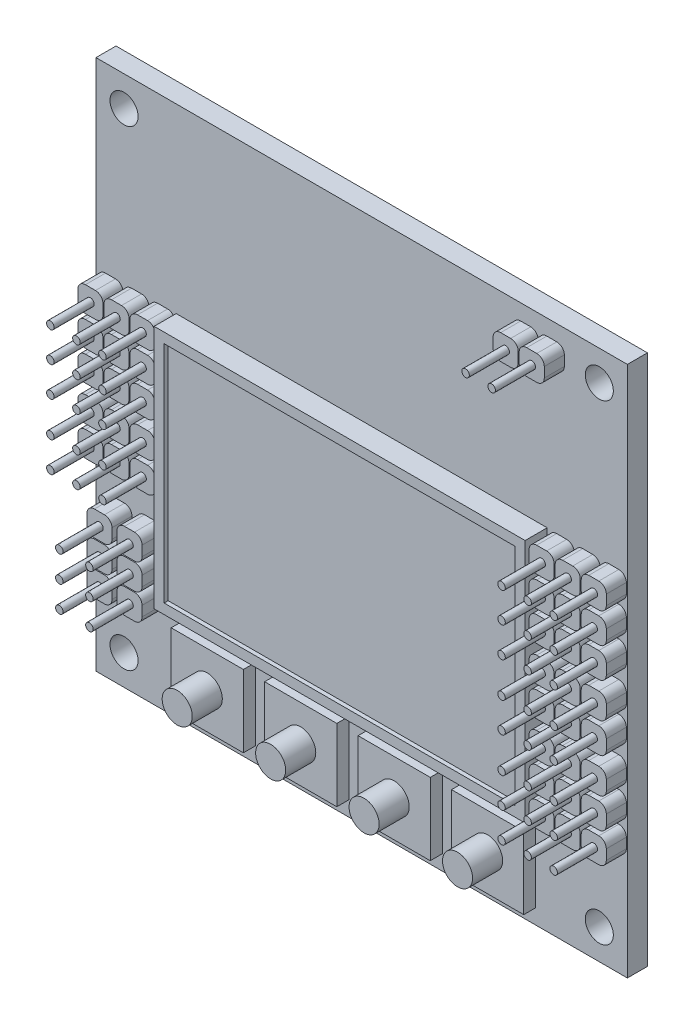
from build123d import *

# Parameters (mm, degrees)
SKETCH1_W                  = 53
SKETCH1_H                  = 53
BOSS_EXTRUDE1_DEPTH        = 2
SKETCH2_R                  = 1.4
CUT_EXTRUDE1_DEPTH         = 2
BOSS_EXTRUDE2_DEPTH        = 2
SKETCH4_R                  = 0.375
BOSS_EXTRUDE3_DEPTH        = 4
LPATTERN1_COUNT            = 3
LPATTERN1_PITCH            = 2.6
LPATTERN2_COUNT            = 3
LPATTERN2_PITCH            = 3
LPATTERN2_COPY_1_DEPTH     = 2
LPATTERN2_COPY_2_DEPTH     = 2
LPATTERN2_COPY_3_DEPTH     = 2
LPATTERN2_COPY_4_DEPTH     = 2
LPATTERN2_COPY_5_SKETCH_R  = 0.375
LPATTERN2_COPY_5_DEPTH     = 4
LPATTERN2_COPY_6_SKETCH_R  = 0.375
LPATTERN2_COPY_6_DEPTH     = 4
LPATTERN2_COPY_7_SKETCH_R  = 0.375
LPATTERN2_COPY_7_DEPTH     = 4
LPATTERN2_COPY_8_SKETCH_R  = 0.375
LPATTERN2_COPY_8_DEPTH     = 4
LPATTERN3_COUNT            = 2
LPATTERN3_PITCH            = 9.5
LPATTERN3_COPY_1_DEPTH     = 2
LPATTERN3_COPY_2_DEPTH     = 2
LPATTERN3_COPY_3_SKETCH_R  = 0.375
LPATTERN3_COPY_3_DEPTH     = 4
LPATTERN3_COPY_4_SKETCH_R  = 0.375
LPATTERN3_COPY_4_DEPTH     = 4
LPATTERN4_COUNT            = 2
LPATTERN4_PITCH            = 12.5
LPATTERN4_COPY_1_DEPTH     = 2
LPATTERN4_COPY_2_DEPTH     = 2
LPATTERN4_COPY_3_SKETCH_R  = 0.375
LPATTERN4_COPY_3_DEPTH     = 4
LPATTERN4_COPY_4_SKETCH_R  = 0.375
LPATTERN4_COPY_4_DEPTH     = 4
LPATTERN5_COUNT            = 2
LPATTERN5_PITCH            = 45
LPATTERN5_COPY_1_DEPTH     = 2
LPATTERN5_COPY_2_SKETCH_R  = 0.375
LPATTERN5_COPY_2_DEPTH     = 4
LPATTERN5_COPY_3_DEPTH     = 2
LPATTERN5_COPY_4_DEPTH     = 2
LPATTERN5_COPY_5_SKETCH_R  = 0.375
LPATTERN5_COPY_5_DEPTH     = 4
LPATTERN5_COPY_6_SKETCH_R  = 0.375
LPATTERN5_COPY_6_DEPTH     = 4
LPATTERN5_COPY_7_DEPTH     = 2
LPATTERN5_COPY_8_SKETCH_R  = 0.375
LPATTERN5_COPY_8_DEPTH     = 4
LPATTERN5_COPY_9_DEPTH     = 2
LPATTERN5_COPY_10_DEPTH    = 2
LPATTERN5_COPY_11_SKETCH_R = 0.375
LPATTERN5_COPY_11_DEPTH    = 4
LPATTERN5_COPY_12_SKETCH_R = 0.375
LPATTERN5_COPY_12_DEPTH    = 4
LPATTERN5_COPY_13_DEPTH    = 2
LPATTERN5_COPY_14_DEPTH    = 2
LPATTERN5_COPY_15_SKETCH_R = 0.375
LPATTERN5_COPY_15_DEPTH    = 4
LPATTERN5_COPY_16_SKETCH_R = 0.375
LPATTERN5_COPY_16_DEPTH    = 4
LPATTERN5_COPY_17_DEPTH    = 2
LPATTERN5_COPY_18_DEPTH    = 2
LPATTERN5_COPY_19_DEPTH    = 2
LPATTERN5_COPY_20_DEPTH    = 2
LPATTERN5_COPY_21_SKETCH_R = 0.375
LPATTERN5_COPY_21_DEPTH    = 4
LPATTERN5_COPY_22_SKETCH_R = 0.375
LPATTERN5_COPY_22_DEPTH    = 4
LPATTERN5_COPY_23_SKETCH_R = 0.375
LPATTERN5_COPY_23_DEPTH    = 4
LPATTERN5_COPY_24_SKETCH_R = 0.375
LPATTERN5_COPY_24_DEPTH    = 4
LPATTERN5_COPY_25_DEPTH    = 2
LPATTERN5_COPY_26_DEPTH    = 2
LPATTERN5_COPY_27_SKETCH_R = 0.375
LPATTERN5_COPY_27_DEPTH    = 4
LPATTERN5_COPY_28_SKETCH_R = 0.375
LPATTERN5_COPY_28_DEPTH    = 4
LPATTERN6_COUNT            = 2
LPATTERN6_PITCH            = 16
LPATTERN6_COPY_1_DEPTH     = 2
LPATTERN6_COPY_2_DEPTH     = 2
LPATTERN6_COPY_3_SKETCH_R  = 0.375
LPATTERN6_COPY_3_DEPTH     = 4
LPATTERN6_COPY_4_SKETCH_R  = 0.375
LPATTERN6_COPY_4_DEPTH     = 4
LPATTERN6_COPY_5_DEPTH     = 2
LPATTERN6_COPY_6_DEPTH     = 2
LPATTERN6_COPY_7_DEPTH     = 2
LPATTERN6_COPY_8_DEPTH     = 2
LPATTERN6_COPY_9_SKETCH_R  = 0.375
LPATTERN6_COPY_9_DEPTH     = 4
LPATTERN6_COPY_10_SKETCH_R = 0.375
LPATTERN6_COPY_10_DEPTH    = 4
LPATTERN6_COPY_11_SKETCH_R = 0.375
LPATTERN6_COPY_11_DEPTH    = 4
LPATTERN6_COPY_12_SKETCH_R = 0.375
LPATTERN6_COPY_12_DEPTH    = 4
LPATTERN6_COPY_13_DEPTH    = 2
LPATTERN6_COPY_14_DEPTH    = 2
LPATTERN6_COPY_15_SKETCH_R = 0.375
LPATTERN6_COPY_15_DEPTH    = 4
LPATTERN6_COPY_16_SKETCH_R = 0.375
LPATTERN6_COPY_16_DEPTH    = 4
SKETCH5_W                  = 7.2
SKETCH5_H                  = 7.2
BOSS_EXTRUDE4_DEPTH        = 1.2
SKETCH6_R                  = 1.5
BOSS_EXTRUDE5_DEPTH        = 3
LPATTERN7_COUNT            = 4
LPATTERN7_PITCH            = 9.32
BOSS_EXTRUDE6_DEPTH        = 2
SKETCH8_R                  = 0.375
BOSS_EXTRUDE7_DEPTH        = 4
LPATTERN8_COUNT            = 2
LPATTERN8_PITCH            = 2.6
SKETCH9_W                  = 37
SKETCH9_H                  = 24.4
BOSS_EXTRUDE8_DEPTH        = 2.2
SKETCH11_W                 = 35
SKETCH11_H                 = 22.4
CUT_EXTRUDE3_DEPTH         = 0.4
BOSS_EXTRUDE9_DEPTH        = 2
SKETCH13_R                 = 0.375
BOSS_EXTRUDE10_DEPTH       = 4
LPATTERN9_COUNT            = 3
LPATTERN9_PITCH            = 2.6
LPATTERN10_COUNT           = 2
LPATTERN10_PITCH           = 3
LPATTERN10_COPY_1_DEPTH    = 2
LPATTERN10_COPY_2_DEPTH    = 2
LPATTERN10_COPY_3_SKETCH_R = 0.375
LPATTERN10_COPY_3_DEPTH    = 4
LPATTERN10_COPY_4_SKETCH_R = 0.375
LPATTERN10_COPY_4_DEPTH    = 4


with BuildPart() as part:
    # Sketch1 → Boss-Extrude1 (new body)
    with BuildSketch(Plane.XY):
        with Locations((26.5, 26.5)):
            Rectangle(SKETCH1_W, SKETCH1_H)
    extrude(amount=BOSS_EXTRUDE1_DEPTH)

    # Sketch2 → Cut-Extrude1 (cut)
    with BuildSketch(Plane.XY.offset(2)):
        with Locations((50.2, 50)):
            Circle(SKETCH2_R)
        with Locations((2.8, 50)):
            Circle(SKETCH2_R)
        with Locations((50.2, 3)):
            Circle(SKETCH2_R)
        with Locations((2.8, 3)):
            Circle(SKETCH2_R)
    extrude(amount=-CUT_EXTRUDE1_DEPTH, mode=Mode.SUBTRACT)

    # Sketch3 → Boss-Extrude2 (add)
    with BuildSketch(Plane.XY.offset(2)):
        with BuildLine():
            Line((45.947892019, 34.858264614), (46.947892019, 34.858264614))
            ThreePointArc((46.947892019, 34.858264614), (47.478222105, 34.6385947), (47.697892019, 34.108264614))
            Line((47.697892019, 34.108264614), (47.697892019, 33.108264614))
            ThreePointArc((47.697892019, 33.108264614), (47.478222105, 32.577934528), (46.947892019, 32.358264614))
            Line((46.947892019, 32.358264614), (45.947892019, 32.358264614))
            ThreePointArc((45.947892019, 32.358264614), (45.417561933, 32.577934528), (45.197892019, 33.108264614))
            Line((45.197892019, 33.108264614), (45.197892019, 34.108264614))
            ThreePointArc((45.197892019, 34.108264614), (45.417561933, 34.6385947), (45.947892019, 34.858264614))
        make_face()
    boss_extrude2 = extrude(amount=BOSS_EXTRUDE2_DEPTH)

    # Sketch4 → Boss-Extrude3 (add)
    with BuildSketch(Plane.XY.offset(4)):
        with Locations((46.447892019, 33.608264614)):
            Circle(SKETCH4_R)
    boss_extrude3 = extrude(amount=BOSS_EXTRUDE3_DEPTH)

    # LPattern1: Boss-Extrude2, Boss-Extrude3 ×3
    with Locations(*[(i * LPATTERN1_PITCH, 0, 0) for i in range(1, LPATTERN1_COUNT)]):
        add(boss_extrude2)
        add(boss_extrude3)

    # LPattern2: Boss-Extrude2, Boss-Extrude3 ×3
    with Locations(*[(0, -i * LPATTERN2_PITCH, 0) for i in range(1, LPATTERN2_COUNT)]):
        add(boss_extrude2)
        add(boss_extrude3)

    # LPattern2 copy 1 sketch → LPattern2 copy 1 (add)
    with BuildSketch(Plane(origin=(2.6, -3, 2), x_dir=(1, 0, 0), z_dir=(0, 0, 1))):
        with BuildLine():
            Line((45.947892019, 34.858264614), (46.947892019, 34.858264614))
            ThreePointArc((46.947892019, 34.858264614), (47.478222105, 34.6385947), (47.697892019, 34.108264614))
            Line((47.697892019, 34.108264614), (47.697892019, 33.108264614))
            ThreePointArc((47.697892019, 33.108264614), (47.478222105, 32.577934528), (46.947892019, 32.358264614))
            Line((46.947892019, 32.358264614), (45.947892019, 32.358264614))
            ThreePointArc((45.947892019, 32.358264614), (45.417561933, 32.577934528), (45.197892019, 33.108264614))
            Line((45.197892019, 33.108264614), (45.197892019, 34.108264614))
            ThreePointArc((45.197892019, 34.108264614), (45.417561933, 34.6385947), (45.947892019, 34.858264614))
        make_face()
    extrude(amount=LPATTERN2_COPY_1_DEPTH)

    # LPattern2 copy 2 sketch → LPattern2 copy 2 (add)
    with BuildSketch(Plane(origin=(2.6, -6, 2), x_dir=(1, 0, 0), z_dir=(0, 0, 1))):
        with BuildLine():
            Line((45.947892019, 34.858264614), (46.947892019, 34.858264614))
            ThreePointArc((46.947892019, 34.858264614), (47.478222105, 34.6385947), (47.697892019, 34.108264614))
            Line((47.697892019, 34.108264614), (47.697892019, 33.108264614))
            ThreePointArc((47.697892019, 33.108264614), (47.478222105, 32.577934528), (46.947892019, 32.358264614))
            Line((46.947892019, 32.358264614), (45.947892019, 32.358264614))
            ThreePointArc((45.947892019, 32.358264614), (45.417561933, 32.577934528), (45.197892019, 33.108264614))
            Line((45.197892019, 33.108264614), (45.197892019, 34.108264614))
            ThreePointArc((45.197892019, 34.108264614), (45.417561933, 34.6385947), (45.947892019, 34.858264614))
        make_face()
    extrude(amount=LPATTERN2_COPY_2_DEPTH)

    # LPattern2 copy 3 sketch → LPattern2 copy 3 (add)
    with BuildSketch(Plane(origin=(5.2, -3, 2), x_dir=(1, 0, 0), z_dir=(0, 0, 1))):
        with BuildLine():
            Line((45.947892019, 34.858264614), (46.947892019, 34.858264614))
            ThreePointArc((46.947892019, 34.858264614), (47.478222105, 34.6385947), (47.697892019, 34.108264614))
            Line((47.697892019, 34.108264614), (47.697892019, 33.108264614))
            ThreePointArc((47.697892019, 33.108264614), (47.478222105, 32.577934528), (46.947892019, 32.358264614))
            Line((46.947892019, 32.358264614), (45.947892019, 32.358264614))
            ThreePointArc((45.947892019, 32.358264614), (45.417561933, 32.577934528), (45.197892019, 33.108264614))
            Line((45.197892019, 33.108264614), (45.197892019, 34.108264614))
            ThreePointArc((45.197892019, 34.108264614), (45.417561933, 34.6385947), (45.947892019, 34.858264614))
        make_face()
    extrude(amount=LPATTERN2_COPY_3_DEPTH)

    # LPattern2 copy 4 sketch → LPattern2 copy 4 (add)
    with BuildSketch(Plane(origin=(5.2, -6, 2), x_dir=(1, 0, 0), z_dir=(0, 0, 1))):
        with BuildLine():
            Line((45.947892019, 34.858264614), (46.947892019, 34.858264614))
            ThreePointArc((46.947892019, 34.858264614), (47.478222105, 34.6385947), (47.697892019, 34.108264614))
            Line((47.697892019, 34.108264614), (47.697892019, 33.108264614))
            ThreePointArc((47.697892019, 33.108264614), (47.478222105, 32.577934528), (46.947892019, 32.358264614))
            Line((46.947892019, 32.358264614), (45.947892019, 32.358264614))
            ThreePointArc((45.947892019, 32.358264614), (45.417561933, 32.577934528), (45.197892019, 33.108264614))
            Line((45.197892019, 33.108264614), (45.197892019, 34.108264614))
            ThreePointArc((45.197892019, 34.108264614), (45.417561933, 34.6385947), (45.947892019, 34.858264614))
        make_face()
    extrude(amount=LPATTERN2_COPY_4_DEPTH)

    # LPattern2 copy 5 sketch → LPattern2 copy 5 (add)
    with BuildSketch(Plane(origin=(2.6, -3, 4), x_dir=(1, 0, 0), z_dir=(0, 0, 1))):
        with Locations((46.447892019, 33.608264614)):
            Circle(LPATTERN2_COPY_5_SKETCH_R)
    extrude(amount=LPATTERN2_COPY_5_DEPTH)

    # LPattern2 copy 6 sketch → LPattern2 copy 6 (add)
    with BuildSketch(Plane(origin=(2.6, -6, 4), x_dir=(1, 0, 0), z_dir=(0, 0, 1))):
        with Locations((46.447892019, 33.608264614)):
            Circle(LPATTERN2_COPY_6_SKETCH_R)
    extrude(amount=LPATTERN2_COPY_6_DEPTH)

    # LPattern2 copy 7 sketch → LPattern2 copy 7 (add)
    with BuildSketch(Plane(origin=(5.2, -3, 4), x_dir=(1, 0, 0), z_dir=(0, 0, 1))):
        with Locations((46.447892019, 33.608264614)):
            Circle(LPATTERN2_COPY_7_SKETCH_R)
    extrude(amount=LPATTERN2_COPY_7_DEPTH)

    # LPattern2 copy 8 sketch → LPattern2 copy 8 (add)
    with BuildSketch(Plane(origin=(5.2, -6, 4), x_dir=(1, 0, 0), z_dir=(0, 0, 1))):
        with Locations((46.447892019, 33.608264614)):
            Circle(LPATTERN2_COPY_8_SKETCH_R)
    extrude(amount=LPATTERN2_COPY_8_DEPTH)

    # LPattern3: Boss-Extrude2, Boss-Extrude3 ×2
    with Locations(*[(0, -i * LPATTERN3_PITCH, 0) for i in range(1, LPATTERN3_COUNT)]):
        add(boss_extrude2)
        add(boss_extrude3)

    # LPattern3 copy 1 sketch → LPattern3 copy 1 (add)
    with BuildSketch(Plane(origin=(2.6, -9.5, 2), x_dir=(1, 0, 0), z_dir=(0, 0, 1))):
        with BuildLine():
            Line((45.947892019, 34.858264614), (46.947892019, 34.858264614))
            ThreePointArc((46.947892019, 34.858264614), (47.478222105, 34.6385947), (47.697892019, 34.108264614))
            Line((47.697892019, 34.108264614), (47.697892019, 33.108264614))
            ThreePointArc((47.697892019, 33.108264614), (47.478222105, 32.577934528), (46.947892019, 32.358264614))
            Line((46.947892019, 32.358264614), (45.947892019, 32.358264614))
            ThreePointArc((45.947892019, 32.358264614), (45.417561933, 32.577934528), (45.197892019, 33.108264614))
            Line((45.197892019, 33.108264614), (45.197892019, 34.108264614))
            ThreePointArc((45.197892019, 34.108264614), (45.417561933, 34.6385947), (45.947892019, 34.858264614))
        make_face()
    extrude(amount=LPATTERN3_COPY_1_DEPTH)

    # LPattern3 copy 2 sketch → LPattern3 copy 2 (add)
    with BuildSketch(Plane(origin=(5.2, -9.5, 2), x_dir=(1, 0, 0), z_dir=(0, 0, 1))):
        with BuildLine():
            Line((45.947892019, 34.858264614), (46.947892019, 34.858264614))
            ThreePointArc((46.947892019, 34.858264614), (47.478222105, 34.6385947), (47.697892019, 34.108264614))
            Line((47.697892019, 34.108264614), (47.697892019, 33.108264614))
            ThreePointArc((47.697892019, 33.108264614), (47.478222105, 32.577934528), (46.947892019, 32.358264614))
            Line((46.947892019, 32.358264614), (45.947892019, 32.358264614))
            ThreePointArc((45.947892019, 32.358264614), (45.417561933, 32.577934528), (45.197892019, 33.108264614))
            Line((45.197892019, 33.108264614), (45.197892019, 34.108264614))
            ThreePointArc((45.197892019, 34.108264614), (45.417561933, 34.6385947), (45.947892019, 34.858264614))
        make_face()
    extrude(amount=LPATTERN3_COPY_2_DEPTH)

    # LPattern3 copy 3 sketch → LPattern3 copy 3 (add)
    with BuildSketch(Plane(origin=(2.6, -9.5, 4), x_dir=(1, 0, 0), z_dir=(0, 0, 1))):
        with Locations((46.447892019, 33.608264614)):
            Circle(LPATTERN3_COPY_3_SKETCH_R)
    extrude(amount=LPATTERN3_COPY_3_DEPTH)

    # LPattern3 copy 4 sketch → LPattern3 copy 4 (add)
    with BuildSketch(Plane(origin=(5.2, -9.5, 4), x_dir=(1, 0, 0), z_dir=(0, 0, 1))):
        with Locations((46.447892019, 33.608264614)):
            Circle(LPATTERN3_COPY_4_SKETCH_R)
    extrude(amount=LPATTERN3_COPY_4_DEPTH)

    # LPattern4: Boss-Extrude2, Boss-Extrude3 ×2
    with Locations(*[(0, -i * LPATTERN4_PITCH, 0) for i in range(1, LPATTERN4_COUNT)]):
        add(boss_extrude2)
        add(boss_extrude3)

    # LPattern4 copy 1 sketch → LPattern4 copy 1 (add)
    with BuildSketch(Plane(origin=(2.6, -12.5, 2), x_dir=(1, 0, 0), z_dir=(0, 0, 1))):
        with BuildLine():
            Line((45.947892019, 34.858264614), (46.947892019, 34.858264614))
            ThreePointArc((46.947892019, 34.858264614), (47.478222105, 34.6385947), (47.697892019, 34.108264614))
            Line((47.697892019, 34.108264614), (47.697892019, 33.108264614))
            ThreePointArc((47.697892019, 33.108264614), (47.478222105, 32.577934528), (46.947892019, 32.358264614))
            Line((46.947892019, 32.358264614), (45.947892019, 32.358264614))
            ThreePointArc((45.947892019, 32.358264614), (45.417561933, 32.577934528), (45.197892019, 33.108264614))
            Line((45.197892019, 33.108264614), (45.197892019, 34.108264614))
            ThreePointArc((45.197892019, 34.108264614), (45.417561933, 34.6385947), (45.947892019, 34.858264614))
        make_face()
    extrude(amount=LPATTERN4_COPY_1_DEPTH)

    # LPattern4 copy 2 sketch → LPattern4 copy 2 (add)
    with BuildSketch(Plane(origin=(5.2, -12.5, 2), x_dir=(1, 0, 0), z_dir=(0, 0, 1))):
        with BuildLine():
            Line((45.947892019, 34.858264614), (46.947892019, 34.858264614))
            ThreePointArc((46.947892019, 34.858264614), (47.478222105, 34.6385947), (47.697892019, 34.108264614))
            Line((47.697892019, 34.108264614), (47.697892019, 33.108264614))
            ThreePointArc((47.697892019, 33.108264614), (47.478222105, 32.577934528), (46.947892019, 32.358264614))
            Line((46.947892019, 32.358264614), (45.947892019, 32.358264614))
            ThreePointArc((45.947892019, 32.358264614), (45.417561933, 32.577934528), (45.197892019, 33.108264614))
            Line((45.197892019, 33.108264614), (45.197892019, 34.108264614))
            ThreePointArc((45.197892019, 34.108264614), (45.417561933, 34.6385947), (45.947892019, 34.858264614))
        make_face()
    extrude(amount=LPATTERN4_COPY_2_DEPTH)

    # LPattern4 copy 3 sketch → LPattern4 copy 3 (add)
    with BuildSketch(Plane(origin=(2.6, -12.5, 4), x_dir=(1, 0, 0), z_dir=(0, 0, 1))):
        with Locations((46.447892019, 33.608264614)):
            Circle(LPATTERN4_COPY_3_SKETCH_R)
    extrude(amount=LPATTERN4_COPY_3_DEPTH)

    # LPattern4 copy 4 sketch → LPattern4 copy 4 (add)
    with BuildSketch(Plane(origin=(5.2, -12.5, 4), x_dir=(1, 0, 0), z_dir=(0, 0, 1))):
        with Locations((46.447892019, 33.608264614)):
            Circle(LPATTERN4_COPY_4_SKETCH_R)
    extrude(amount=LPATTERN4_COPY_4_DEPTH)

    # LPattern5: Boss-Extrude2, Boss-Extrude3 ×2
    with Locations(*[(-i * LPATTERN5_PITCH, 0, 0) for i in range(1, LPATTERN5_COUNT)]):
        add(boss_extrude2)
        add(boss_extrude3)

    # LPattern5 copy 1 sketch → LPattern5 copy 1 (add)
    with BuildSketch(Plane(origin=(-45, -12.5, 2), x_dir=(1, 0, 0), z_dir=(0, 0, 1))):
        with BuildLine():
            Line((45.947892019, 34.858264614), (46.947892019, 34.858264614))
            ThreePointArc((46.947892019, 34.858264614), (47.478222105, 34.6385947), (47.697892019, 34.108264614))
            Line((47.697892019, 34.108264614), (47.697892019, 33.108264614))
            ThreePointArc((47.697892019, 33.108264614), (47.478222105, 32.577934528), (46.947892019, 32.358264614))
            Line((46.947892019, 32.358264614), (45.947892019, 32.358264614))
            ThreePointArc((45.947892019, 32.358264614), (45.417561933, 32.577934528), (45.197892019, 33.108264614))
            Line((45.197892019, 33.108264614), (45.197892019, 34.108264614))
            ThreePointArc((45.197892019, 34.108264614), (45.417561933, 34.6385947), (45.947892019, 34.858264614))
        make_face()
    extrude(amount=LPATTERN5_COPY_1_DEPTH)

    # LPattern5 copy 2 sketch → LPattern5 copy 2 (add)
    with BuildSketch(Plane(origin=(-45, -12.5, 4), x_dir=(1, 0, 0), z_dir=(0, 0, 1))):
        with Locations((46.447892019, 33.608264614)):
            Circle(LPATTERN5_COPY_2_SKETCH_R)
    extrude(amount=LPATTERN5_COPY_2_DEPTH)

    # LPattern5 copy 3 sketch → LPattern5 copy 3 (add)
    with BuildSketch(Plane(origin=(-42.4, -12.5, 2), x_dir=(1, 0, 0), z_dir=(0, 0, 1))):
        with BuildLine():
            Line((45.947892019, 34.858264614), (46.947892019, 34.858264614))
            ThreePointArc((46.947892019, 34.858264614), (47.478222105, 34.6385947), (47.697892019, 34.108264614))
            Line((47.697892019, 34.108264614), (47.697892019, 33.108264614))
            ThreePointArc((47.697892019, 33.108264614), (47.478222105, 32.577934528), (46.947892019, 32.358264614))
            Line((46.947892019, 32.358264614), (45.947892019, 32.358264614))
            ThreePointArc((45.947892019, 32.358264614), (45.417561933, 32.577934528), (45.197892019, 33.108264614))
            Line((45.197892019, 33.108264614), (45.197892019, 34.108264614))
            ThreePointArc((45.197892019, 34.108264614), (45.417561933, 34.6385947), (45.947892019, 34.858264614))
        make_face()
    extrude(amount=LPATTERN5_COPY_3_DEPTH)

    # LPattern5 copy 4 sketch → LPattern5 copy 4 (add)
    with BuildSketch(Plane(origin=(-39.8, -12.5, 2), x_dir=(1, 0, 0), z_dir=(0, 0, 1))):
        with BuildLine():
            Line((45.947892019, 34.858264614), (46.947892019, 34.858264614))
            ThreePointArc((46.947892019, 34.858264614), (47.478222105, 34.6385947), (47.697892019, 34.108264614))
            Line((47.697892019, 34.108264614), (47.697892019, 33.108264614))
            ThreePointArc((47.697892019, 33.108264614), (47.478222105, 32.577934528), (46.947892019, 32.358264614))
            Line((46.947892019, 32.358264614), (45.947892019, 32.358264614))
            ThreePointArc((45.947892019, 32.358264614), (45.417561933, 32.577934528), (45.197892019, 33.108264614))
            Line((45.197892019, 33.108264614), (45.197892019, 34.108264614))
            ThreePointArc((45.197892019, 34.108264614), (45.417561933, 34.6385947), (45.947892019, 34.858264614))
        make_face()
    extrude(amount=LPATTERN5_COPY_4_DEPTH)

    # LPattern5 copy 5 sketch → LPattern5 copy 5 (add)
    with BuildSketch(Plane(origin=(-42.4, -12.5, 4), x_dir=(1, 0, 0), z_dir=(0, 0, 1))):
        with Locations((46.447892019, 33.608264614)):
            Circle(LPATTERN5_COPY_5_SKETCH_R)
    extrude(amount=LPATTERN5_COPY_5_DEPTH)

    # LPattern5 copy 6 sketch → LPattern5 copy 6 (add)
    with BuildSketch(Plane(origin=(-39.8, -12.5, 4), x_dir=(1, 0, 0), z_dir=(0, 0, 1))):
        with Locations((46.447892019, 33.608264614)):
            Circle(LPATTERN5_COPY_6_SKETCH_R)
    extrude(amount=LPATTERN5_COPY_6_DEPTH)

    # LPattern5 copy 7 sketch → LPattern5 copy 7 (add)
    with BuildSketch(Plane(origin=(-45, -9.5, 2), x_dir=(1, 0, 0), z_dir=(0, 0, 1))):
        with BuildLine():
            Line((45.947892019, 34.858264614), (46.947892019, 34.858264614))
            ThreePointArc((46.947892019, 34.858264614), (47.478222105, 34.6385947), (47.697892019, 34.108264614))
            Line((47.697892019, 34.108264614), (47.697892019, 33.108264614))
            ThreePointArc((47.697892019, 33.108264614), (47.478222105, 32.577934528), (46.947892019, 32.358264614))
            Line((46.947892019, 32.358264614), (45.947892019, 32.358264614))
            ThreePointArc((45.947892019, 32.358264614), (45.417561933, 32.577934528), (45.197892019, 33.108264614))
            Line((45.197892019, 33.108264614), (45.197892019, 34.108264614))
            ThreePointArc((45.197892019, 34.108264614), (45.417561933, 34.6385947), (45.947892019, 34.858264614))
        make_face()
    extrude(amount=LPATTERN5_COPY_7_DEPTH)

    # LPattern5 copy 8 sketch → LPattern5 copy 8 (add)
    with BuildSketch(Plane(origin=(-45, -9.5, 4), x_dir=(1, 0, 0), z_dir=(0, 0, 1))):
        with Locations((46.447892019, 33.608264614)):
            Circle(LPATTERN5_COPY_8_SKETCH_R)
    extrude(amount=LPATTERN5_COPY_8_DEPTH)

    # LPattern5 copy 9 sketch → LPattern5 copy 9 (add)
    with BuildSketch(Plane(origin=(-42.4, -9.5, 2), x_dir=(1, 0, 0), z_dir=(0, 0, 1))):
        with BuildLine():
            Line((45.947892019, 34.858264614), (46.947892019, 34.858264614))
            ThreePointArc((46.947892019, 34.858264614), (47.478222105, 34.6385947), (47.697892019, 34.108264614))
            Line((47.697892019, 34.108264614), (47.697892019, 33.108264614))
            ThreePointArc((47.697892019, 33.108264614), (47.478222105, 32.577934528), (46.947892019, 32.358264614))
            Line((46.947892019, 32.358264614), (45.947892019, 32.358264614))
            ThreePointArc((45.947892019, 32.358264614), (45.417561933, 32.577934528), (45.197892019, 33.108264614))
            Line((45.197892019, 33.108264614), (45.197892019, 34.108264614))
            ThreePointArc((45.197892019, 34.108264614), (45.417561933, 34.6385947), (45.947892019, 34.858264614))
        make_face()
    extrude(amount=LPATTERN5_COPY_9_DEPTH)

    # LPattern5 copy 10 sketch → LPattern5 copy 10 (add)
    with BuildSketch(Plane(origin=(-39.8, -9.5, 2), x_dir=(1, 0, 0), z_dir=(0, 0, 1))):
        with BuildLine():
            Line((45.947892019, 34.858264614), (46.947892019, 34.858264614))
            ThreePointArc((46.947892019, 34.858264614), (47.478222105, 34.6385947), (47.697892019, 34.108264614))
            Line((47.697892019, 34.108264614), (47.697892019, 33.108264614))
            ThreePointArc((47.697892019, 33.108264614), (47.478222105, 32.577934528), (46.947892019, 32.358264614))
            Line((46.947892019, 32.358264614), (45.947892019, 32.358264614))
            ThreePointArc((45.947892019, 32.358264614), (45.417561933, 32.577934528), (45.197892019, 33.108264614))
            Line((45.197892019, 33.108264614), (45.197892019, 34.108264614))
            ThreePointArc((45.197892019, 34.108264614), (45.417561933, 34.6385947), (45.947892019, 34.858264614))
        make_face()
    extrude(amount=LPATTERN5_COPY_10_DEPTH)

    # LPattern5 copy 11 sketch → LPattern5 copy 11 (add)
    with BuildSketch(Plane(origin=(-42.4, -9.5, 4), x_dir=(1, 0, 0), z_dir=(0, 0, 1))):
        with Locations((46.447892019, 33.608264614)):
            Circle(LPATTERN5_COPY_11_SKETCH_R)
    extrude(amount=LPATTERN5_COPY_11_DEPTH)

    # LPattern5 copy 12 sketch → LPattern5 copy 12 (add)
    with BuildSketch(Plane(origin=(-39.8, -9.5, 4), x_dir=(1, 0, 0), z_dir=(0, 0, 1))):
        with Locations((46.447892019, 33.608264614)):
            Circle(LPATTERN5_COPY_12_SKETCH_R)
    extrude(amount=LPATTERN5_COPY_12_DEPTH)

    # LPattern5 copy 13 sketch → LPattern5 copy 13 (add)
    with BuildSketch(Plane(origin=(-45, -3, 2), x_dir=(1, 0, 0), z_dir=(0, 0, 1))):
        with BuildLine():
            Line((45.947892019, 34.858264614), (46.947892019, 34.858264614))
            ThreePointArc((46.947892019, 34.858264614), (47.478222105, 34.6385947), (47.697892019, 34.108264614))
            Line((47.697892019, 34.108264614), (47.697892019, 33.108264614))
            ThreePointArc((47.697892019, 33.108264614), (47.478222105, 32.577934528), (46.947892019, 32.358264614))
            Line((46.947892019, 32.358264614), (45.947892019, 32.358264614))
            ThreePointArc((45.947892019, 32.358264614), (45.417561933, 32.577934528), (45.197892019, 33.108264614))
            Line((45.197892019, 33.108264614), (45.197892019, 34.108264614))
            ThreePointArc((45.197892019, 34.108264614), (45.417561933, 34.6385947), (45.947892019, 34.858264614))
        make_face()
    extrude(amount=LPATTERN5_COPY_13_DEPTH)

    # LPattern5 copy 14 sketch → LPattern5 copy 14 (add)
    with BuildSketch(Plane(origin=(-45, -6, 2), x_dir=(1, 0, 0), z_dir=(0, 0, 1))):
        with BuildLine():
            Line((45.947892019, 34.858264614), (46.947892019, 34.858264614))
            ThreePointArc((46.947892019, 34.858264614), (47.478222105, 34.6385947), (47.697892019, 34.108264614))
            Line((47.697892019, 34.108264614), (47.697892019, 33.108264614))
            ThreePointArc((47.697892019, 33.108264614), (47.478222105, 32.577934528), (46.947892019, 32.358264614))
            Line((46.947892019, 32.358264614), (45.947892019, 32.358264614))
            ThreePointArc((45.947892019, 32.358264614), (45.417561933, 32.577934528), (45.197892019, 33.108264614))
            Line((45.197892019, 33.108264614), (45.197892019, 34.108264614))
            ThreePointArc((45.197892019, 34.108264614), (45.417561933, 34.6385947), (45.947892019, 34.858264614))
        make_face()
    extrude(amount=LPATTERN5_COPY_14_DEPTH)

    # LPattern5 copy 15 sketch → LPattern5 copy 15 (add)
    with BuildSketch(Plane(origin=(-45, -3, 4), x_dir=(1, 0, 0), z_dir=(0, 0, 1))):
        with Locations((46.447892019, 33.608264614)):
            Circle(LPATTERN5_COPY_15_SKETCH_R)
    extrude(amount=LPATTERN5_COPY_15_DEPTH)

    # LPattern5 copy 16 sketch → LPattern5 copy 16 (add)
    with BuildSketch(Plane(origin=(-45, -6, 4), x_dir=(1, 0, 0), z_dir=(0, 0, 1))):
        with Locations((46.447892019, 33.608264614)):
            Circle(LPATTERN5_COPY_16_SKETCH_R)
    extrude(amount=LPATTERN5_COPY_16_DEPTH)

    # LPattern5 copy 17 sketch → LPattern5 copy 17 (add)
    with BuildSketch(Plane(origin=(-42.4, -3, 2), x_dir=(1, 0, 0), z_dir=(0, 0, 1))):
        with BuildLine():
            Line((45.947892019, 34.858264614), (46.947892019, 34.858264614))
            ThreePointArc((46.947892019, 34.858264614), (47.478222105, 34.6385947), (47.697892019, 34.108264614))
            Line((47.697892019, 34.108264614), (47.697892019, 33.108264614))
            ThreePointArc((47.697892019, 33.108264614), (47.478222105, 32.577934528), (46.947892019, 32.358264614))
            Line((46.947892019, 32.358264614), (45.947892019, 32.358264614))
            ThreePointArc((45.947892019, 32.358264614), (45.417561933, 32.577934528), (45.197892019, 33.108264614))
            Line((45.197892019, 33.108264614), (45.197892019, 34.108264614))
            ThreePointArc((45.197892019, 34.108264614), (45.417561933, 34.6385947), (45.947892019, 34.858264614))
        make_face()
    extrude(amount=LPATTERN5_COPY_17_DEPTH)

    # LPattern5 copy 18 sketch → LPattern5 copy 18 (add)
    with BuildSketch(Plane(origin=(-42.4, -6, 2), x_dir=(1, 0, 0), z_dir=(0, 0, 1))):
        with BuildLine():
            Line((45.947892019, 34.858264614), (46.947892019, 34.858264614))
            ThreePointArc((46.947892019, 34.858264614), (47.478222105, 34.6385947), (47.697892019, 34.108264614))
            Line((47.697892019, 34.108264614), (47.697892019, 33.108264614))
            ThreePointArc((47.697892019, 33.108264614), (47.478222105, 32.577934528), (46.947892019, 32.358264614))
            Line((46.947892019, 32.358264614), (45.947892019, 32.358264614))
            ThreePointArc((45.947892019, 32.358264614), (45.417561933, 32.577934528), (45.197892019, 33.108264614))
            Line((45.197892019, 33.108264614), (45.197892019, 34.108264614))
            ThreePointArc((45.197892019, 34.108264614), (45.417561933, 34.6385947), (45.947892019, 34.858264614))
        make_face()
    extrude(amount=LPATTERN5_COPY_18_DEPTH)

    # LPattern5 copy 19 sketch → LPattern5 copy 19 (add)
    with BuildSketch(Plane(origin=(-39.8, -3, 2), x_dir=(1, 0, 0), z_dir=(0, 0, 1))):
        with BuildLine():
            Line((45.947892019, 34.858264614), (46.947892019, 34.858264614))
            ThreePointArc((46.947892019, 34.858264614), (47.478222105, 34.6385947), (47.697892019, 34.108264614))
            Line((47.697892019, 34.108264614), (47.697892019, 33.108264614))
            ThreePointArc((47.697892019, 33.108264614), (47.478222105, 32.577934528), (46.947892019, 32.358264614))
            Line((46.947892019, 32.358264614), (45.947892019, 32.358264614))
            ThreePointArc((45.947892019, 32.358264614), (45.417561933, 32.577934528), (45.197892019, 33.108264614))
            Line((45.197892019, 33.108264614), (45.197892019, 34.108264614))
            ThreePointArc((45.197892019, 34.108264614), (45.417561933, 34.6385947), (45.947892019, 34.858264614))
        make_face()
    extrude(amount=LPATTERN5_COPY_19_DEPTH)

    # LPattern5 copy 20 sketch → LPattern5 copy 20 (add)
    with BuildSketch(Plane(origin=(-39.8, -6, 2), x_dir=(1, 0, 0), z_dir=(0, 0, 1))):
        with BuildLine():
            Line((45.947892019, 34.858264614), (46.947892019, 34.858264614))
            ThreePointArc((46.947892019, 34.858264614), (47.478222105, 34.6385947), (47.697892019, 34.108264614))
            Line((47.697892019, 34.108264614), (47.697892019, 33.108264614))
            ThreePointArc((47.697892019, 33.108264614), (47.478222105, 32.577934528), (46.947892019, 32.358264614))
            Line((46.947892019, 32.358264614), (45.947892019, 32.358264614))
            ThreePointArc((45.947892019, 32.358264614), (45.417561933, 32.577934528), (45.197892019, 33.108264614))
            Line((45.197892019, 33.108264614), (45.197892019, 34.108264614))
            ThreePointArc((45.197892019, 34.108264614), (45.417561933, 34.6385947), (45.947892019, 34.858264614))
        make_face()
    extrude(amount=LPATTERN5_COPY_20_DEPTH)

    # LPattern5 copy 21 sketch → LPattern5 copy 21 (add)
    with BuildSketch(Plane(origin=(-42.4, -3, 4), x_dir=(1, 0, 0), z_dir=(0, 0, 1))):
        with Locations((46.447892019, 33.608264614)):
            Circle(LPATTERN5_COPY_21_SKETCH_R)
    extrude(amount=LPATTERN5_COPY_21_DEPTH)

    # LPattern5 copy 22 sketch → LPattern5 copy 22 (add)
    with BuildSketch(Plane(origin=(-42.4, -6, 4), x_dir=(1, 0, 0), z_dir=(0, 0, 1))):
        with Locations((46.447892019, 33.608264614)):
            Circle(LPATTERN5_COPY_22_SKETCH_R)
    extrude(amount=LPATTERN5_COPY_22_DEPTH)

    # LPattern5 copy 23 sketch → LPattern5 copy 23 (add)
    with BuildSketch(Plane(origin=(-39.8, -3, 4), x_dir=(1, 0, 0), z_dir=(0, 0, 1))):
        with Locations((46.447892019, 33.608264614)):
            Circle(LPATTERN5_COPY_23_SKETCH_R)
    extrude(amount=LPATTERN5_COPY_23_DEPTH)

    # LPattern5 copy 24 sketch → LPattern5 copy 24 (add)
    with BuildSketch(Plane(origin=(-39.8, -6, 4), x_dir=(1, 0, 0), z_dir=(0, 0, 1))):
        with Locations((46.447892019, 33.608264614)):
            Circle(LPATTERN5_COPY_24_SKETCH_R)
    extrude(amount=LPATTERN5_COPY_24_DEPTH)

    # LPattern5 copy 25 sketch → LPattern5 copy 25 (add)
    with BuildSketch(Plane(origin=(-42.4, 0, 2), x_dir=(1, 0, 0), z_dir=(0, 0, 1))):
        with BuildLine():
            Line((45.947892019, 34.858264614), (46.947892019, 34.858264614))
            ThreePointArc((46.947892019, 34.858264614), (47.478222105, 34.6385947), (47.697892019, 34.108264614))
            Line((47.697892019, 34.108264614), (47.697892019, 33.108264614))
            ThreePointArc((47.697892019, 33.108264614), (47.478222105, 32.577934528), (46.947892019, 32.358264614))
            Line((46.947892019, 32.358264614), (45.947892019, 32.358264614))
            ThreePointArc((45.947892019, 32.358264614), (45.417561933, 32.577934528), (45.197892019, 33.108264614))
            Line((45.197892019, 33.108264614), (45.197892019, 34.108264614))
            ThreePointArc((45.197892019, 34.108264614), (45.417561933, 34.6385947), (45.947892019, 34.858264614))
        make_face()
    extrude(amount=LPATTERN5_COPY_25_DEPTH)

    # LPattern5 copy 26 sketch → LPattern5 copy 26 (add)
    with BuildSketch(Plane(origin=(-39.8, 0, 2), x_dir=(1, 0, 0), z_dir=(0, 0, 1))):
        with BuildLine():
            Line((45.947892019, 34.858264614), (46.947892019, 34.858264614))
            ThreePointArc((46.947892019, 34.858264614), (47.478222105, 34.6385947), (47.697892019, 34.108264614))
            Line((47.697892019, 34.108264614), (47.697892019, 33.108264614))
            ThreePointArc((47.697892019, 33.108264614), (47.478222105, 32.577934528), (46.947892019, 32.358264614))
            Line((46.947892019, 32.358264614), (45.947892019, 32.358264614))
            ThreePointArc((45.947892019, 32.358264614), (45.417561933, 32.577934528), (45.197892019, 33.108264614))
            Line((45.197892019, 33.108264614), (45.197892019, 34.108264614))
            ThreePointArc((45.197892019, 34.108264614), (45.417561933, 34.6385947), (45.947892019, 34.858264614))
        make_face()
    extrude(amount=LPATTERN5_COPY_26_DEPTH)

    # LPattern5 copy 27 sketch → LPattern5 copy 27 (add)
    with BuildSketch(Plane(origin=(-42.4, 0, 4), x_dir=(1, 0, 0), z_dir=(0, 0, 1))):
        with Locations((46.447892019, 33.608264614)):
            Circle(LPATTERN5_COPY_27_SKETCH_R)
    extrude(amount=LPATTERN5_COPY_27_DEPTH)

    # LPattern5 copy 28 sketch → LPattern5 copy 28 (add)
    with BuildSketch(Plane(origin=(-39.8, 0, 4), x_dir=(1, 0, 0), z_dir=(0, 0, 1))):
        with Locations((46.447892019, 33.608264614)):
            Circle(LPATTERN5_COPY_28_SKETCH_R)
    extrude(amount=LPATTERN5_COPY_28_DEPTH)

    # LPattern6: Boss-Extrude2, Boss-Extrude3 ×2
    with Locations(*[(0, -i * LPATTERN6_PITCH, 0) for i in range(1, LPATTERN6_COUNT)]):
        add(boss_extrude2)
        add(boss_extrude3)

    # LPattern6 copy 1 sketch → LPattern6 copy 1 (add)
    with BuildSketch(Plane(origin=(0, -19, 2), x_dir=(1, 0, 0), z_dir=(0, 0, 1))):
        with BuildLine():
            Line((45.947892019, 34.858264614), (46.947892019, 34.858264614))
            ThreePointArc((46.947892019, 34.858264614), (47.478222105, 34.6385947), (47.697892019, 34.108264614))
            Line((47.697892019, 34.108264614), (47.697892019, 33.108264614))
            ThreePointArc((47.697892019, 33.108264614), (47.478222105, 32.577934528), (46.947892019, 32.358264614))
            Line((46.947892019, 32.358264614), (45.947892019, 32.358264614))
            ThreePointArc((45.947892019, 32.358264614), (45.417561933, 32.577934528), (45.197892019, 33.108264614))
            Line((45.197892019, 33.108264614), (45.197892019, 34.108264614))
            ThreePointArc((45.197892019, 34.108264614), (45.417561933, 34.6385947), (45.947892019, 34.858264614))
        make_face()
    extrude(amount=LPATTERN6_COPY_1_DEPTH)

    # LPattern6 copy 2 sketch → LPattern6 copy 2 (add)
    with BuildSketch(Plane(origin=(0, -22, 2), x_dir=(1, 0, 0), z_dir=(0, 0, 1))):
        with BuildLine():
            Line((45.947892019, 34.858264614), (46.947892019, 34.858264614))
            ThreePointArc((46.947892019, 34.858264614), (47.478222105, 34.6385947), (47.697892019, 34.108264614))
            Line((47.697892019, 34.108264614), (47.697892019, 33.108264614))
            ThreePointArc((47.697892019, 33.108264614), (47.478222105, 32.577934528), (46.947892019, 32.358264614))
            Line((46.947892019, 32.358264614), (45.947892019, 32.358264614))
            ThreePointArc((45.947892019, 32.358264614), (45.417561933, 32.577934528), (45.197892019, 33.108264614))
            Line((45.197892019, 33.108264614), (45.197892019, 34.108264614))
            ThreePointArc((45.197892019, 34.108264614), (45.417561933, 34.6385947), (45.947892019, 34.858264614))
        make_face()
    extrude(amount=LPATTERN6_COPY_2_DEPTH)

    # LPattern6 copy 3 sketch → LPattern6 copy 3 (add)
    with BuildSketch(Plane(origin=(0, -19, 4), x_dir=(1, 0, 0), z_dir=(0, 0, 1))):
        with Locations((46.447892019, 33.608264614)):
            Circle(LPATTERN6_COPY_3_SKETCH_R)
    extrude(amount=LPATTERN6_COPY_3_DEPTH)

    # LPattern6 copy 4 sketch → LPattern6 copy 4 (add)
    with BuildSketch(Plane(origin=(0, -22, 4), x_dir=(1, 0, 0), z_dir=(0, 0, 1))):
        with Locations((46.447892019, 33.608264614)):
            Circle(LPATTERN6_COPY_4_SKETCH_R)
    extrude(amount=LPATTERN6_COPY_4_DEPTH)

    # LPattern6 copy 5 sketch → LPattern6 copy 5 (add)
    with BuildSketch(Plane(origin=(2.6, -19, 2), x_dir=(1, 0, 0), z_dir=(0, 0, 1))):
        with BuildLine():
            Line((45.947892019, 34.858264614), (46.947892019, 34.858264614))
            ThreePointArc((46.947892019, 34.858264614), (47.478222105, 34.6385947), (47.697892019, 34.108264614))
            Line((47.697892019, 34.108264614), (47.697892019, 33.108264614))
            ThreePointArc((47.697892019, 33.108264614), (47.478222105, 32.577934528), (46.947892019, 32.358264614))
            Line((46.947892019, 32.358264614), (45.947892019, 32.358264614))
            ThreePointArc((45.947892019, 32.358264614), (45.417561933, 32.577934528), (45.197892019, 33.108264614))
            Line((45.197892019, 33.108264614), (45.197892019, 34.108264614))
            ThreePointArc((45.197892019, 34.108264614), (45.417561933, 34.6385947), (45.947892019, 34.858264614))
        make_face()
    extrude(amount=LPATTERN6_COPY_5_DEPTH)

    # LPattern6 copy 6 sketch → LPattern6 copy 6 (add)
    with BuildSketch(Plane(origin=(2.6, -22, 2), x_dir=(1, 0, 0), z_dir=(0, 0, 1))):
        with BuildLine():
            Line((45.947892019, 34.858264614), (46.947892019, 34.858264614))
            ThreePointArc((46.947892019, 34.858264614), (47.478222105, 34.6385947), (47.697892019, 34.108264614))
            Line((47.697892019, 34.108264614), (47.697892019, 33.108264614))
            ThreePointArc((47.697892019, 33.108264614), (47.478222105, 32.577934528), (46.947892019, 32.358264614))
            Line((46.947892019, 32.358264614), (45.947892019, 32.358264614))
            ThreePointArc((45.947892019, 32.358264614), (45.417561933, 32.577934528), (45.197892019, 33.108264614))
            Line((45.197892019, 33.108264614), (45.197892019, 34.108264614))
            ThreePointArc((45.197892019, 34.108264614), (45.417561933, 34.6385947), (45.947892019, 34.858264614))
        make_face()
    extrude(amount=LPATTERN6_COPY_6_DEPTH)

    # LPattern6 copy 7 sketch → LPattern6 copy 7 (add)
    with BuildSketch(Plane(origin=(5.2, -19, 2), x_dir=(1, 0, 0), z_dir=(0, 0, 1))):
        with BuildLine():
            Line((45.947892019, 34.858264614), (46.947892019, 34.858264614))
            ThreePointArc((46.947892019, 34.858264614), (47.478222105, 34.6385947), (47.697892019, 34.108264614))
            Line((47.697892019, 34.108264614), (47.697892019, 33.108264614))
            ThreePointArc((47.697892019, 33.108264614), (47.478222105, 32.577934528), (46.947892019, 32.358264614))
            Line((46.947892019, 32.358264614), (45.947892019, 32.358264614))
            ThreePointArc((45.947892019, 32.358264614), (45.417561933, 32.577934528), (45.197892019, 33.108264614))
            Line((45.197892019, 33.108264614), (45.197892019, 34.108264614))
            ThreePointArc((45.197892019, 34.108264614), (45.417561933, 34.6385947), (45.947892019, 34.858264614))
        make_face()
    extrude(amount=LPATTERN6_COPY_7_DEPTH)

    # LPattern6 copy 8 sketch → LPattern6 copy 8 (add)
    with BuildSketch(Plane(origin=(5.2, -22, 2), x_dir=(1, 0, 0), z_dir=(0, 0, 1))):
        with BuildLine():
            Line((45.947892019, 34.858264614), (46.947892019, 34.858264614))
            ThreePointArc((46.947892019, 34.858264614), (47.478222105, 34.6385947), (47.697892019, 34.108264614))
            Line((47.697892019, 34.108264614), (47.697892019, 33.108264614))
            ThreePointArc((47.697892019, 33.108264614), (47.478222105, 32.577934528), (46.947892019, 32.358264614))
            Line((46.947892019, 32.358264614), (45.947892019, 32.358264614))
            ThreePointArc((45.947892019, 32.358264614), (45.417561933, 32.577934528), (45.197892019, 33.108264614))
            Line((45.197892019, 33.108264614), (45.197892019, 34.108264614))
            ThreePointArc((45.197892019, 34.108264614), (45.417561933, 34.6385947), (45.947892019, 34.858264614))
        make_face()
    extrude(amount=LPATTERN6_COPY_8_DEPTH)

    # LPattern6 copy 9 sketch → LPattern6 copy 9 (add)
    with BuildSketch(Plane(origin=(2.6, -19, 4), x_dir=(1, 0, 0), z_dir=(0, 0, 1))):
        with Locations((46.447892019, 33.608264614)):
            Circle(LPATTERN6_COPY_9_SKETCH_R)
    extrude(amount=LPATTERN6_COPY_9_DEPTH)

    # LPattern6 copy 10 sketch → LPattern6 copy 10 (add)
    with BuildSketch(Plane(origin=(2.6, -22, 4), x_dir=(1, 0, 0), z_dir=(0, 0, 1))):
        with Locations((46.447892019, 33.608264614)):
            Circle(LPATTERN6_COPY_10_SKETCH_R)
    extrude(amount=LPATTERN6_COPY_10_DEPTH)

    # LPattern6 copy 11 sketch → LPattern6 copy 11 (add)
    with BuildSketch(Plane(origin=(5.2, -19, 4), x_dir=(1, 0, 0), z_dir=(0, 0, 1))):
        with Locations((46.447892019, 33.608264614)):
            Circle(LPATTERN6_COPY_11_SKETCH_R)
    extrude(amount=LPATTERN6_COPY_11_DEPTH)

    # LPattern6 copy 12 sketch → LPattern6 copy 12 (add)
    with BuildSketch(Plane(origin=(5.2, -22, 4), x_dir=(1, 0, 0), z_dir=(0, 0, 1))):
        with Locations((46.447892019, 33.608264614)):
            Circle(LPATTERN6_COPY_12_SKETCH_R)
    extrude(amount=LPATTERN6_COPY_12_DEPTH)

    # LPattern6 copy 13 sketch → LPattern6 copy 13 (add)
    with BuildSketch(Plane(origin=(2.6, -16, 2), x_dir=(1, 0, 0), z_dir=(0, 0, 1))):
        with BuildLine():
            Line((45.947892019, 34.858264614), (46.947892019, 34.858264614))
            ThreePointArc((46.947892019, 34.858264614), (47.478222105, 34.6385947), (47.697892019, 34.108264614))
            Line((47.697892019, 34.108264614), (47.697892019, 33.108264614))
            ThreePointArc((47.697892019, 33.108264614), (47.478222105, 32.577934528), (46.947892019, 32.358264614))
            Line((46.947892019, 32.358264614), (45.947892019, 32.358264614))
            ThreePointArc((45.947892019, 32.358264614), (45.417561933, 32.577934528), (45.197892019, 33.108264614))
            Line((45.197892019, 33.108264614), (45.197892019, 34.108264614))
            ThreePointArc((45.197892019, 34.108264614), (45.417561933, 34.6385947), (45.947892019, 34.858264614))
        make_face()
    extrude(amount=LPATTERN6_COPY_13_DEPTH)

    # LPattern6 copy 14 sketch → LPattern6 copy 14 (add)
    with BuildSketch(Plane(origin=(5.2, -16, 2), x_dir=(1, 0, 0), z_dir=(0, 0, 1))):
        with BuildLine():
            Line((45.947892019, 34.858264614), (46.947892019, 34.858264614))
            ThreePointArc((46.947892019, 34.858264614), (47.478222105, 34.6385947), (47.697892019, 34.108264614))
            Line((47.697892019, 34.108264614), (47.697892019, 33.108264614))
            ThreePointArc((47.697892019, 33.108264614), (47.478222105, 32.577934528), (46.947892019, 32.358264614))
            Line((46.947892019, 32.358264614), (45.947892019, 32.358264614))
            ThreePointArc((45.947892019, 32.358264614), (45.417561933, 32.577934528), (45.197892019, 33.108264614))
            Line((45.197892019, 33.108264614), (45.197892019, 34.108264614))
            ThreePointArc((45.197892019, 34.108264614), (45.417561933, 34.6385947), (45.947892019, 34.858264614))
        make_face()
    extrude(amount=LPATTERN6_COPY_14_DEPTH)

    # LPattern6 copy 15 sketch → LPattern6 copy 15 (add)
    with BuildSketch(Plane(origin=(2.6, -16, 4), x_dir=(1, 0, 0), z_dir=(0, 0, 1))):
        with Locations((46.447892019, 33.608264614)):
            Circle(LPATTERN6_COPY_15_SKETCH_R)
    extrude(amount=LPATTERN6_COPY_15_DEPTH)

    # LPattern6 copy 16 sketch → LPattern6 copy 16 (add)
    with BuildSketch(Plane(origin=(5.2, -16, 4), x_dir=(1, 0, 0), z_dir=(0, 0, 1))):
        with Locations((46.447892019, 33.608264614)):
            Circle(LPATTERN6_COPY_16_SKETCH_R)
    extrude(amount=LPATTERN6_COPY_16_DEPTH)

    # Sketch5 → Boss-Extrude4 (add)
    with BuildSketch(Plane.XY.offset(2)):
        with Locations((12.301442191, 5.101442191)):
            Rectangle(SKETCH5_W, SKETCH5_H)
    boss_extrude4 = extrude(amount=BOSS_EXTRUDE4_DEPTH)

    # Sketch6 → Boss-Extrude5 (add)
    with BuildSketch(Plane.XY.offset(3.2)):
        with Locations((12.301442191, 5.101442191)):
            Circle(SKETCH6_R)
    boss_extrude5 = extrude(amount=BOSS_EXTRUDE5_DEPTH)

    # LPattern7: Boss-Extrude4, Boss-Extrude5 ×4
    with Locations(*[(i * LPATTERN7_PITCH, 0, 0) for i in range(1, LPATTERN7_COUNT)]):
        add(boss_extrude4)
        add(boss_extrude5)

    # Sketch7 → Boss-Extrude6 (add)
    with BuildSketch(Plane.XY.offset(2)):
        with BuildLine():
            Line((42.362161751, 51.42606479), (43.362161751, 51.42606479))
            ThreePointArc((43.362161751, 51.42606479), (43.892491837, 51.206394876), (44.112161751, 50.67606479))
            Line((44.112161751, 50.67606479), (44.112161751, 49.67606479))
            ThreePointArc((44.112161751, 49.67606479), (43.892491837, 49.145734705), (43.362161751, 48.92606479))
            Line((43.362161751, 48.92606479), (42.362161751, 48.92606479))
            ThreePointArc((42.362161751, 48.92606479), (41.831831666, 49.145734705), (41.612161751, 49.67606479))
            Line((41.612161751, 49.67606479), (41.612161751, 50.67606479))
            ThreePointArc((41.612161751, 50.67606479), (41.831831666, 51.206394876), (42.362161751, 51.42606479))
        make_face()
    boss_extrude6 = extrude(amount=BOSS_EXTRUDE6_DEPTH)

    # Sketch8 → Boss-Extrude7 (add)
    with BuildSketch(Plane.XY.offset(4)):
        with Locations((42.862161751, 50.17606479)):
            Circle(SKETCH8_R)
    boss_extrude7 = extrude(amount=BOSS_EXTRUDE7_DEPTH)

    # LPattern8: Boss-Extrude6, Boss-Extrude7 ×2
    with Locations(*[(i * LPATTERN8_PITCH, 0, 0) for i in range(1, LPATTERN8_COUNT)]):
        add(boss_extrude6)
        add(boss_extrude7)

    # Sketch9 → Boss-Extrude8 (add)
    with BuildSketch(Plane.XY.offset(2)):
        with Locations((26.5, 22.687781973)):
            Rectangle(SKETCH9_W, SKETCH9_H)
    extrude(amount=BOSS_EXTRUDE8_DEPTH)

    # Sketch11 → Cut-Extrude3 (cut)
    with BuildSketch(Plane.XY.offset(4.2)):
        with Locations((26.5, 22.687781973)):
            Rectangle(SKETCH11_W, SKETCH11_H)
    extrude(amount=-CUT_EXTRUDE3_DEPTH, mode=Mode.SUBTRACT)

    # Sketch12 → Boss-Extrude9 (add)
    with BuildSketch(Plane.XY.offset(2)):
        with BuildLine():
            Line((1.845662146, 15.935247003), (2.845662146, 15.935247003))
            ThreePointArc((2.845662146, 15.935247003), (3.375992232, 15.715577089), (3.595662146, 15.185247003))
            Line((3.595662146, 15.185247003), (3.595662146, 14.185247003))
            ThreePointArc((3.595662146, 14.185247003), (3.375992232, 13.654916917), (2.845662146, 13.435247003))
            Line((2.845662146, 13.435247003), (1.845662146, 13.435247003))
            ThreePointArc((1.845662146, 13.435247003), (1.31533206, 13.654916917), (1.095662146, 14.185247003))
            Line((1.095662146, 14.185247003), (1.095662146, 15.185247003))
            ThreePointArc((1.095662146, 15.185247003), (1.31533206, 15.715577089), (1.845662146, 15.935247003))
        make_face()
    boss_extrude9 = extrude(amount=BOSS_EXTRUDE9_DEPTH)

    # Sketch13 → Boss-Extrude10 (add)
    with BuildSketch(Plane.XY.offset(4)):
        with Locations((2.345662146, 14.685247003)):
            Circle(SKETCH13_R)
    boss_extrude10 = extrude(amount=BOSS_EXTRUDE10_DEPTH)

    # LPattern9: Boss-Extrude9, Boss-Extrude10 ×3
    with Locations(*[(0, -i * LPATTERN9_PITCH, 0) for i in range(1, LPATTERN9_COUNT)]):
        add(boss_extrude9)
        add(boss_extrude10)

    # LPattern10: Boss-Extrude9, Boss-Extrude10 ×2
    with Locations(*[(i * LPATTERN10_PITCH, 0, 0) for i in range(1, LPATTERN10_COUNT)]):
        add(boss_extrude9)
        add(boss_extrude10)

    # LPattern10 copy 1 sketch → LPattern10 copy 1 (add)
    with BuildSketch(Plane(origin=(3, -2.6, 2), x_dir=(1, 0, 0), z_dir=(0, 0, 1))):
        with BuildLine():
            Line((1.845662146, 15.935247003), (2.845662146, 15.935247003))
            ThreePointArc((2.845662146, 15.935247003), (3.375992232, 15.715577089), (3.595662146, 15.185247003))
            Line((3.595662146, 15.185247003), (3.595662146, 14.185247003))
            ThreePointArc((3.595662146, 14.185247003), (3.375992232, 13.654916917), (2.845662146, 13.435247003))
            Line((2.845662146, 13.435247003), (1.845662146, 13.435247003))
            ThreePointArc((1.845662146, 13.435247003), (1.31533206, 13.654916917), (1.095662146, 14.185247003))
            Line((1.095662146, 14.185247003), (1.095662146, 15.185247003))
            ThreePointArc((1.095662146, 15.185247003), (1.31533206, 15.715577089), (1.845662146, 15.935247003))
        make_face()
    extrude(amount=LPATTERN10_COPY_1_DEPTH)

    # LPattern10 copy 2 sketch → LPattern10 copy 2 (add)
    with BuildSketch(Plane(origin=(3, -5.2, 2), x_dir=(1, 0, 0), z_dir=(0, 0, 1))):
        with BuildLine():
            Line((1.845662146, 15.935247003), (2.845662146, 15.935247003))
            ThreePointArc((2.845662146, 15.935247003), (3.375992232, 15.715577089), (3.595662146, 15.185247003))
            Line((3.595662146, 15.185247003), (3.595662146, 14.185247003))
            ThreePointArc((3.595662146, 14.185247003), (3.375992232, 13.654916917), (2.845662146, 13.435247003))
            Line((2.845662146, 13.435247003), (1.845662146, 13.435247003))
            ThreePointArc((1.845662146, 13.435247003), (1.31533206, 13.654916917), (1.095662146, 14.185247003))
            Line((1.095662146, 14.185247003), (1.095662146, 15.185247003))
            ThreePointArc((1.095662146, 15.185247003), (1.31533206, 15.715577089), (1.845662146, 15.935247003))
        make_face()
    extrude(amount=LPATTERN10_COPY_2_DEPTH)

    # LPattern10 copy 3 sketch → LPattern10 copy 3 (add)
    with BuildSketch(Plane(origin=(3, -2.6, 4), x_dir=(1, 0, 0), z_dir=(0, 0, 1))):
        with Locations((2.345662146, 14.685247003)):
            Circle(LPATTERN10_COPY_3_SKETCH_R)
    extrude(amount=LPATTERN10_COPY_3_DEPTH)

    # LPattern10 copy 4 sketch → LPattern10 copy 4 (add)
    with BuildSketch(Plane(origin=(3, -5.2, 4), x_dir=(1, 0, 0), z_dir=(0, 0, 1))):
        with Locations((2.345662146, 14.685247003)):
            Circle(LPATTERN10_COPY_4_SKETCH_R)
    extrude(amount=LPATTERN10_COPY_4_DEPTH)


solid = part.part
